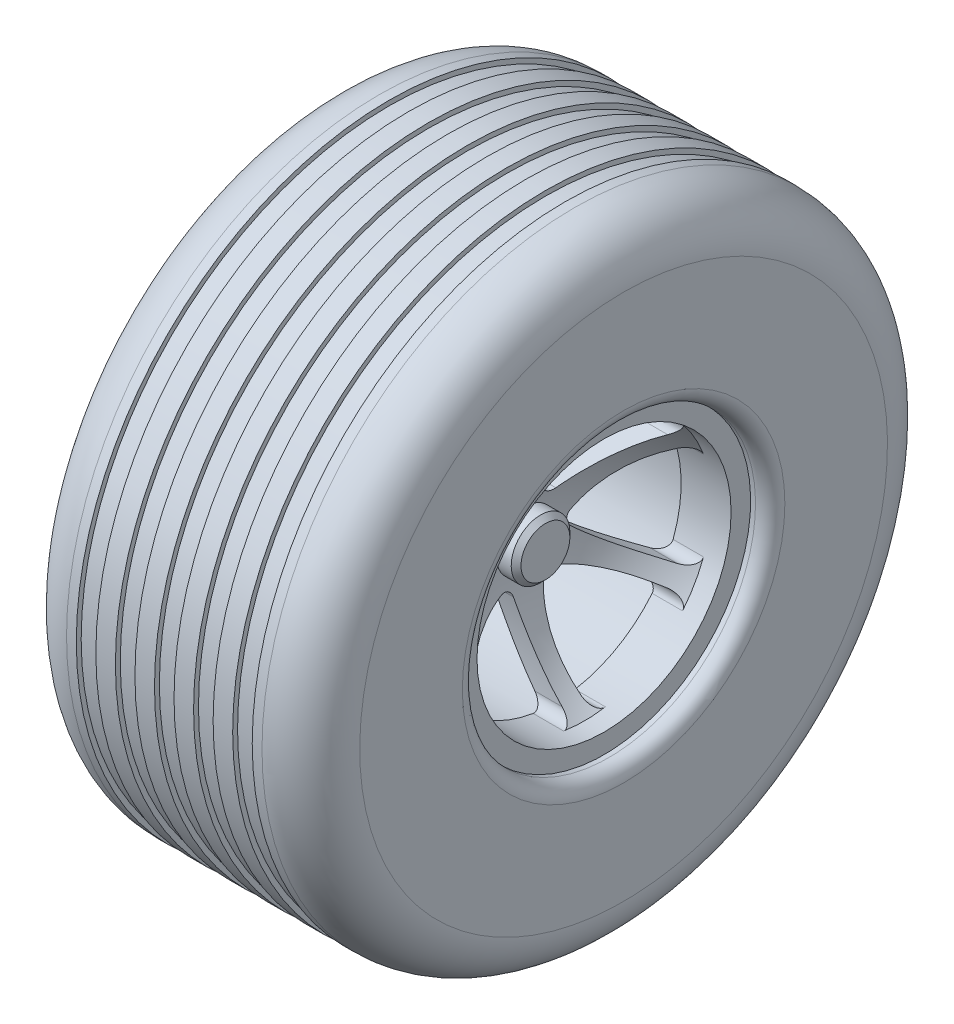
from build123d import *

# Parameters (mm, degrees)
CHAMFER1_SIZE      = 0.5
CUT_EXTRUDE2_DEPTH = 40


with BuildPart() as part:
    # Sketch1 → Revolve1 (revolve)
    with BuildSketch(Plane.XY):
        with BuildLine():
            Line((-8, 0), (-30, 0))
            Line((-30, 0), (-30, 3))
            Line((-30, 3), (-15, 3))
            ThreePointArc((-15, 3), (-19.181324, 9.450543), (-26, 13))
            Line((-26, 13), (-28, 13))
            Line((-28, 13), (-28, 15))
            Line((-28, 15), (-28.5, 15))
            ThreePointArc((-28.5, 15), (-29.56066, 15.43934), (-30, 16.5))
            Line((-30, 16.5), (-30, 27))
            ThreePointArc((-30, 27), (-28.535534, 30.535534), (-25, 32))
            Line((-25, 32), (-24, 32))
            Line((-24, 32), (-24, 31.5))
            Line((-24, 31.5), (-22, 31.5))
            Line((-22, 31.5), (-22, 32))
            Line((-22, 32), (-20, 32))
            Line((-20, 32), (-20, 31.5))
            Line((-20, 31.5), (-18, 31.5))
            Line((-18, 31.5), (-18, 32))
            Line((-18, 32), (-16, 32))
            Line((-16, 32), (-16, 31.5))
            Line((-16, 31.5), (-14, 31.5))
            Line((-14, 31.5), (-14, 32))
            Line((-14, 32), (-12, 32))
            Line((-12, 32), (-12, 31.5))
            Line((-12, 31.5), (-10, 31.5))
            Line((-10, 31.5), (-10, 32))
            Line((-10, 32), (-8, 32))
            Line((-8, 32), (-8, 31.5))
            Line((-8, 31.5), (-6, 31.5))
            Line((-6, 31.5), (-6, 32))
            Line((-6, 32), (-5, 32))
            ThreePointArc((-5, 32), (-1.464466, 30.535534), (0, 27))
            Line((0, 27), (0, 16.5))
            ThreePointArc((0, 16.5), (-0.43934, 15.43934), (-1.5, 15))
            Line((-1.5, 15), (-2, 15))
            Line((-2, 15), (-2, 13))
            Line((-2, 13), (-4, 13))
            ThreePointArc((-4, 13), (-8.042472, 8.625483), (-10, 3))
            Line((-10, 3), (-8, 3))
            Line((-8, 3), (-8, 0))
        make_face()
        with BuildLine():
            Line((-13.099809, 3.623918), (-11.931551, 3.623918))
            ThreePointArc((-11.931551, 3.623918), (-9.661486, 9.812426), (-5.160894, 14.628596))
            Line((-5.160894, 14.628596), (-24.342867, 14.628596))
            ThreePointArc((-24.342867, 14.628596), (-17.378152, 10.498538), (-13.099809, 3.623918))
        make_face(mode=Mode.SUBTRACT)
    revolve(axis=Axis((-8, 0, 0), (-1, 0, 0)))

    # Chamfer1
    chamfer1_edges = [part.edges().sort_by_distance(p)[0] for p in [
        (-8, -3, 0),
    ]]
    chamfer(chamfer1_edges, length=CHAMFER1_SIZE)

    # Sketch2 → Cut-Extrude2 (cut)
    with BuildSketch(Plane(origin=(-2, 0, 0), x_dir=(0, 0, -1), z_dir=(1, 0, 0))):
        with BuildLine():
            ThreePointArc((-0.981174, 11.907052), (-1.360078, 12.621497), (-2.143514, 12.822065))
            ThreePointArc((-2.143514, 12.822065), (-6.5, 11.25833), (-10.032477, 8.26737))
            ThreePointArc((-10.032477, 8.26737), (-10.250498, 7.48861), (-9.821223, 6.803247))
            ThreePointArc((-9.821223, 6.803247), (-6.436788, 4.845732), (-2.810603, 3.383868))
            ThreePointArc((-2.810603, 3.383868), (-2.003042, 3.469371), (-1.525214, 4.125988))
            ThreePointArc((-1.525214, 4.125988), (-0.978133, 7.997288), (-0.981174, 11.907052))
        make_face()
        with BuildLine():
            ThreePointArc((1.525214, 4.125988), (2.003042, 3.469371), (2.810603, 3.383868))
            ThreePointArc((2.810603, 3.383868), (6.436788, 4.845732), (9.821223, 6.803247))
            ThreePointArc((9.821223, 6.803247), (10.250498, 7.48861), (10.032477, 8.26737))
            ThreePointArc((10.032477, 8.26737), (6.5, 11.25833), (2.143514, 12.822065))
            ThreePointArc((2.143514, 12.822065), (1.360078, 12.621497), (0.981174, 11.907052))
            ThreePointArc((0.981174, 11.907052), (0.978133, 7.997288), (1.525214, 4.125988))
        make_face()
        with BuildLine():
            ThreePointArc((12.175991, 4.554695), (11.610576, 5.132887), (10.802396, 5.103805))
            ThreePointArc((10.802396, 5.103805), (7.414921, 3.151556), (4.335817, 0.74212))
            ThreePointArc((4.335817, 0.74212), (4.006085, 0), (4.335817, -0.74212))
            ThreePointArc((4.335817, -0.74212), (7.414921, -3.151556), (10.802396, -5.103805))
            ThreePointArc((10.802396, -5.103805), (11.610576, -5.132887), (12.175991, -4.554695))
            ThreePointArc((12.175991, -4.554695), (13, 0), (12.175991, 4.554695))
        make_face()
        with BuildLine():
            ThreePointArc((10.032477, -8.26737), (10.250498, -7.48861), (9.821223, -6.803247))
            ThreePointArc((9.821223, -6.803247), (6.436788, -4.845732), (2.810603, -3.383868))
            ThreePointArc((2.810603, -3.383868), (2.003042, -3.469371), (1.525214, -4.125988))
            ThreePointArc((1.525214, -4.125988), (0.978133, -7.997288), (0.981174, -11.907052))
            ThreePointArc((0.981174, -11.907052), (1.360078, -12.621497), (2.143514, -12.822065))
            ThreePointArc((2.143514, -12.822065), (6.5, -11.25833), (10.032477, -8.26737))
        make_face()
        with BuildLine():
            ThreePointArc((-2.143514, -12.822065), (-1.360078, -12.621497), (-0.981174, -11.907052))
            ThreePointArc((-0.981174, -11.907052), (-0.978133, -7.997288), (-1.525214, -4.125988))
            ThreePointArc((-1.525214, -4.125988), (-2.003042, -3.469371), (-2.810603, -3.383868))
            ThreePointArc((-2.810603, -3.383868), (-6.436788, -4.845732), (-9.821223, -6.803247))
            ThreePointArc((-9.821223, -6.803247), (-10.250498, -7.48861), (-10.032477, -8.26737))
            ThreePointArc((-10.032477, -8.26737), (-6.5, -11.25833), (-2.143514, -12.822065))
        make_face()
        with BuildLine():
            ThreePointArc((-12.175991, -4.554695), (-11.610576, -5.132887), (-10.802396, -5.103805))
            ThreePointArc((-10.802396, -5.103805), (-7.414921, -3.151556), (-4.335817, -0.74212))
            ThreePointArc((-4.335817, -0.74212), (-4.006085, 0), (-4.335817, 0.74212))
            ThreePointArc((-4.335817, 0.74212), (-7.414921, 3.151556), (-10.802396, 5.103805))
            ThreePointArc((-10.802396, 5.103805), (-11.610576, 5.132887), (-12.175991, 4.554695))
            ThreePointArc((-12.175991, 4.554695), (-13, 0), (-12.175991, -4.554695))
        make_face()
    extrude(amount=-CUT_EXTRUDE2_DEPTH, mode=Mode.SUBTRACT)


solid = part.part
